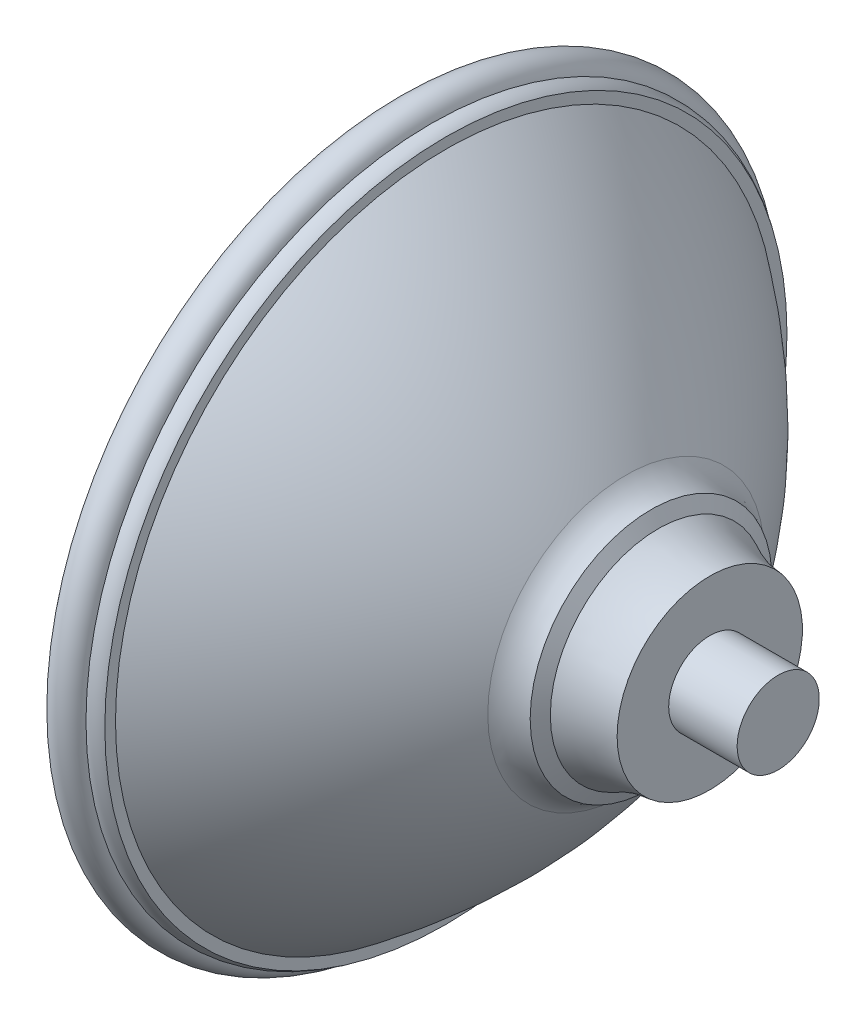
from build123d import *


with BuildPart() as part:
    # Sketch2 → Revolve1 (revolve)
    with BuildSketch(Plane.XY):
        with BuildLine():
            Line((-25.597437633, 0), (0, 0))
            Line((0, 0), (73.976965745, 0))
            Line((73.976965745, 0), (73.976965745, 8.299770962))
            Line((73.976965745, 8.299770962), (60.152752801, 8.299770962))
            Line((60.152752801, 8.299770962), (60.152752801, 18.718018398))
            ThreePointArc((60.152752801, 18.718018398), (54.777031462, 19.685959858), (49.73670358, 21.790807934))
            Line((49.73670358, 21.790807934), (48.294773312, 24.424720864))
            ThreePointArc((48.294773312, 24.424720864), (45.461812474, 25.740504528), (43.231317585, 27.927247839))
            ThreePointArc((43.231317585, 27.927247839), (26.824133992, 49.008029455), (6.848945256, 66.744626138))
            Line((6.848945256, 66.744626138), (6.848945256, 68.90061568))
            ThreePointArc((6.848945256, 68.90061568), (5.454689471, 69.611741476), (3.896001293, 69.753657831))
            ThreePointArc((3.896001293, 69.753657831), (0.098650433, 72.567937412), (-3.328634224, 69.313131275))
            ThreePointArc((-3.328634224, 69.313131275), (-3.611089688, 68.347310313), (-3.959539112, 67.403290069))
            ThreePointArc((-3.959539112, 67.403290069), (-20.030277748, 35.387581811), (-25.597437633, 0))
        make_face()
    revolve(axis=Axis((0, 0, 0), (1, 0, 0)))


solid = part.part
